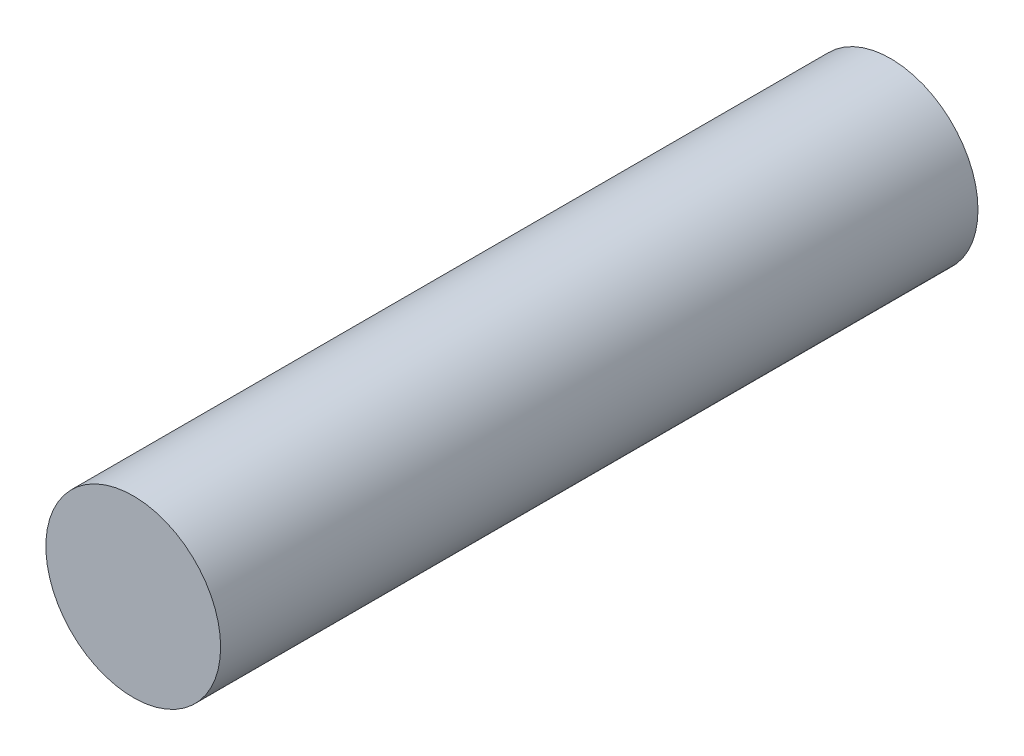
from build123d import *

# Parameters (mm, degrees)
SKETCH_1_R      = 2.25
EXTRUDE_1_DEPTH = 19.5


with BuildPart() as part:
    # Эскиз1 → Бобышка-Вытянуть1 (new body)
    with BuildSketch(Plane.XY):
        Circle(SKETCH_1_R)
    extrude(amount=EXTRUDE_1_DEPTH)


solid = part.part
